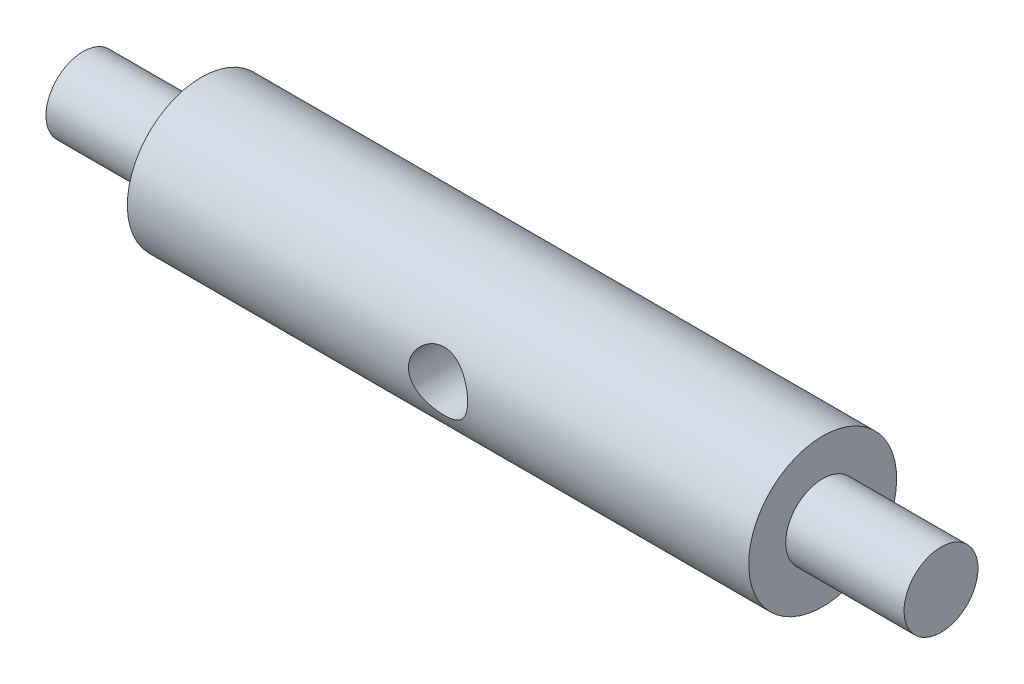
from build123d import *

# Parameters (mm, degrees)
SKETCH_3_R          = 2
CUT_EXTRUDE_1_DEPTH = 10


with BuildPart() as part:
    # 草圖1 → 旋轉1 (revolve)
    with BuildSketch(Plane.XY):
        Polygon((-29, 0), (-29, 2.5), (-21, 2.5), (-21, 5), (21, 5), (21, 2.5), (29, 2.5), (29, 0), align=None)
    revolve(axis=Axis((29, 0, 0), (-1, 0, 0)))

    # 草圖3 → 除料-伸長1 (cut, symmetric)
    with BuildSketch(Plane.XY):
        Circle(SKETCH_3_R)
    extrude(amount=CUT_EXTRUDE_1_DEPTH, both=True, mode=Mode.SUBTRACT)


solid = part.part
